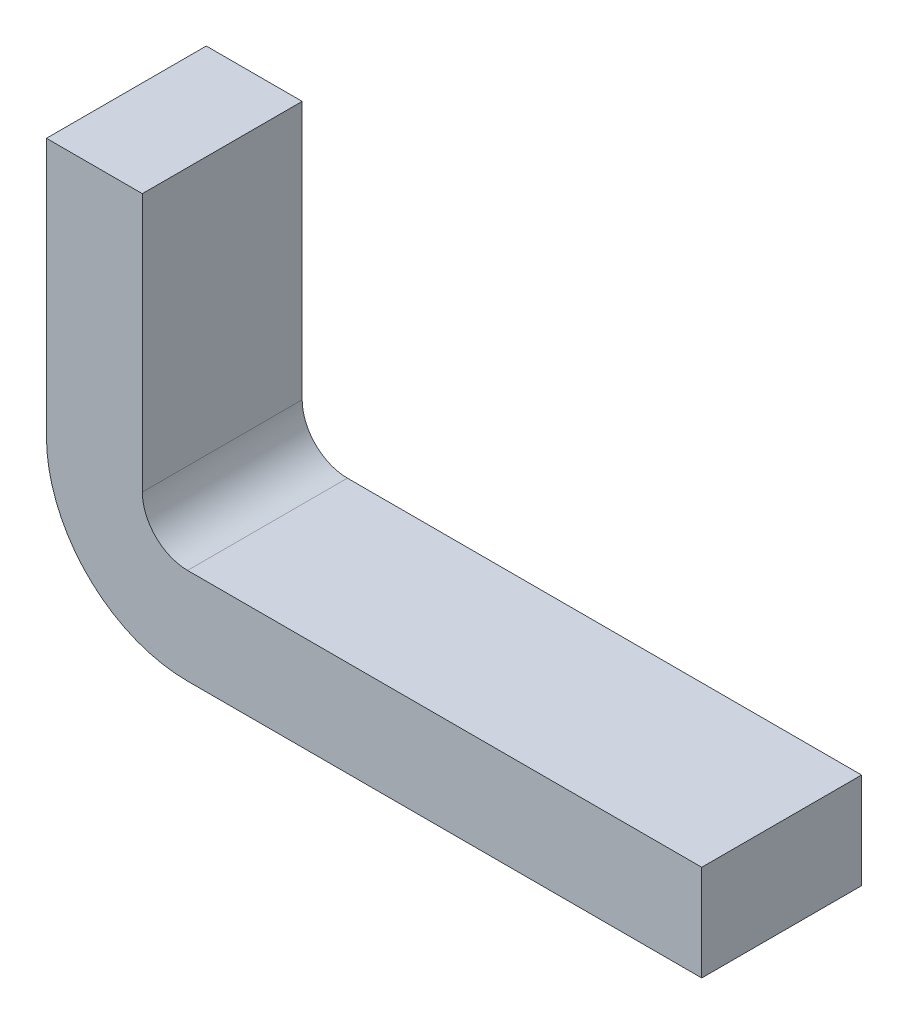
from build123d import *

# Parameters (mm, degrees)
SALIENTE_EXTRUIR1_DEPTH      = 0.25
SALIENTE_EXTRUIR1_DEPTH_BACK = 0.25


with BuildPart() as part:
    # Croquis1 → Saliente-Extruir1 (new body, two sides)
    with BuildSketch(Plane.XY) as saliente_extruir1_sk:
        with BuildLine():
            Line((1.9, 0.3), (0.291547595, 0.3))
            ThreePointArc((0.291547595, 0.3), (0.191458331, 0.341458331), (0.15, 0.441547595))
            Line((0.15, 0.441547595), (0.15, 1.25))
            Line((0.15, 1.25), (-0.15, 1.25))
            Line((-0.15, 1.25), (-0.15, 0.441547595))
            ThreePointArc((-0.15, 0.441547595), (-0.020673704, 0.129326296), (0.291547595, 0))
            Line((0.291547595, 0), (1.9, 0))
            Line((1.9, 0), (1.9, 0.3))
        make_face()
    extrude(amount=SALIENTE_EXTRUIR1_DEPTH)
    extrude(saliente_extruir1_sk.sketch, amount=-SALIENTE_EXTRUIR1_DEPTH_BACK)


solid = part.part
